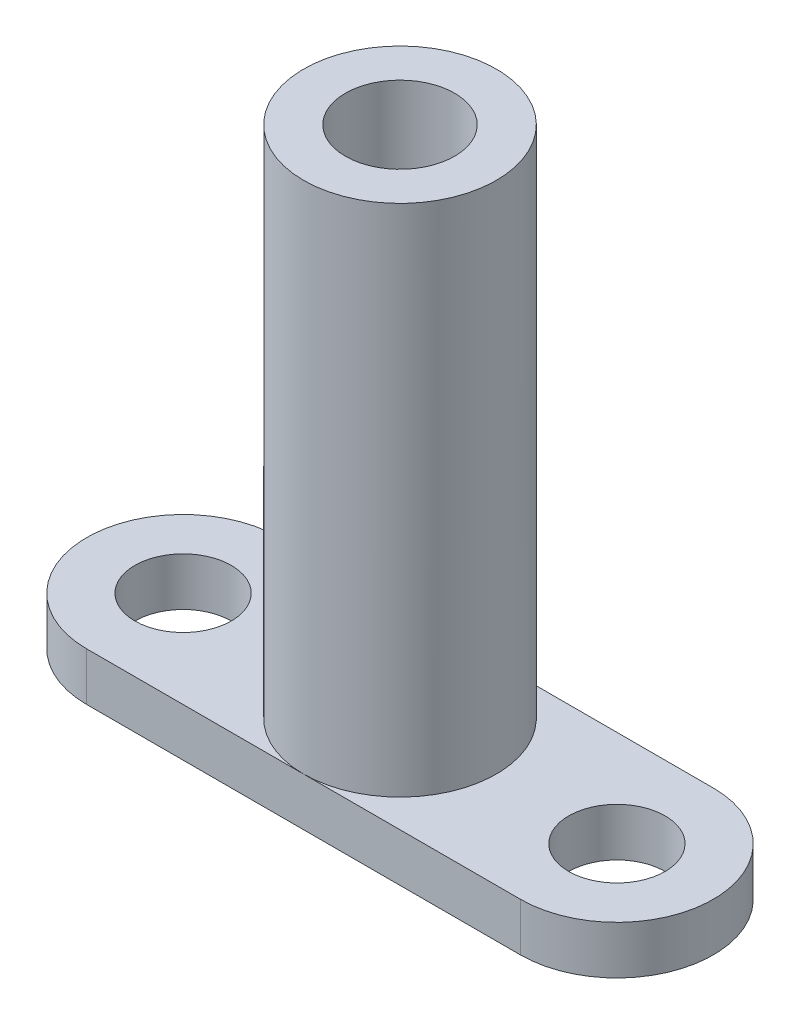
from build123d import *

# Parameters (mm, degrees)
SKETCH_1_R          = 6
EXTRUDE_1_DEPTH     = 3
SKETCH_2_R          = 6
EXTRUDE_2_DEPTH     = 32
HOLE_WIZARD_M8_1_D  = 6.8
SKETCH_6_R          = 3
CUT_EXTRUDE_1_DEPTH = 10


with BuildPart() as part:
    # 草图1 → 凸台-拉伸1 (new body)
    with BuildSketch(Plane(origin=(0, 0, 0), x_dir=(1, 0, 0), z_dir=(0, 1, 0))):
        with Locations((-13.5, 0)):
            Circle(SKETCH_1_R)
        with BuildLine():
            Line((13.5, 6), (-13.5, 6))
            ThreePointArc((-13.5, 6), (-9.257359313, 4.242640687), (-7.5, 0))
            ThreePointArc((-7.5, 0), (-9.257359313, -4.242640687), (-13.5, -6))
            Line((-13.5, -6), (13.5, -6))
            ThreePointArc((13.5, -6), (7.5, 0), (13.5, 6))
        make_face()
        with Locations((13.5, 0)):
            Circle(SKETCH_1_R)
    extrude(amount=EXTRUDE_1_DEPTH)

    # 草图2 → 凸台-拉伸2 (add)
    with BuildSketch(Plane(origin=(0, 3, 0), x_dir=(1, 0, 0), z_dir=(0, 1, 0))):
        Circle(SKETCH_2_R)
    extrude(amount=EXTRUDE_2_DEPTH)

    # M8 螺纹孔1 (through all)
    with Locations(Plane(origin=(0, 35, 0), x_dir=(1, 0, 0), z_dir=(0, 1, 0))):
        with Locations((0, 0)):
            Hole(HOLE_WIZARD_M8_1_D / 2)

    # 草图6 → 切除-拉伸1 (cut)
    with BuildSketch(Plane(origin=(0, 3, 0), x_dir=(1, 0, 0), z_dir=(0, 1, 0))):
        with Locations((-13.5, 0)):
            Circle(SKETCH_6_R)
        with Locations((13.5, 0)):
            Circle(SKETCH_6_R)
    extrude(amount=-CUT_EXTRUDE_1_DEPTH, mode=Mode.SUBTRACT)


solid = part.part
